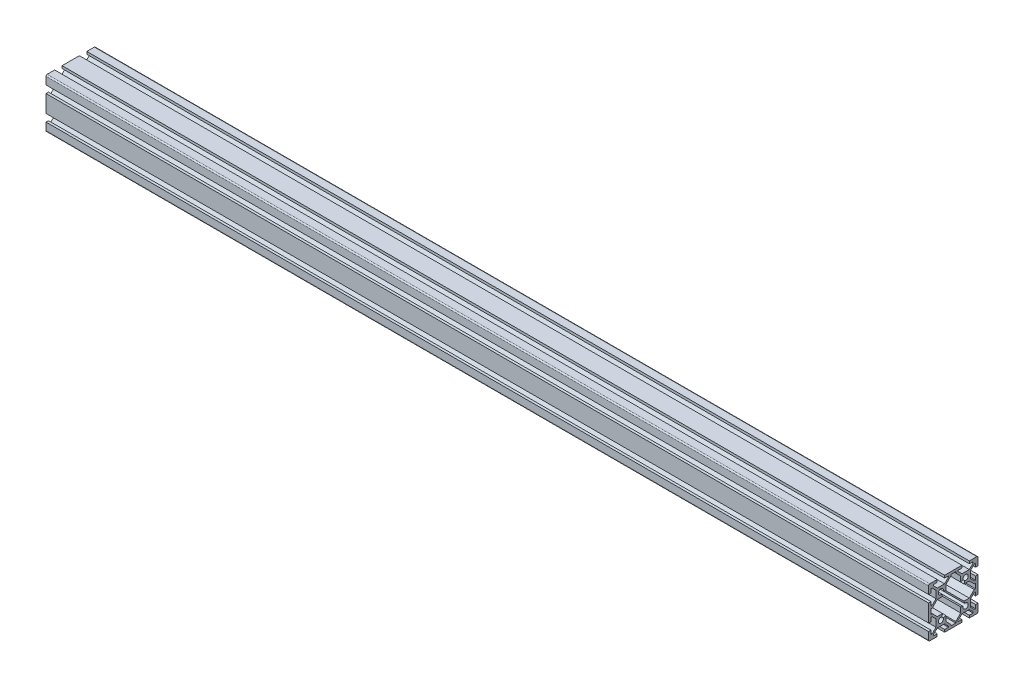
from build123d import *

# Parameters (mm, degrees)
BOSS_EXTRUDE1_DEPTH = 714


with BuildPart() as part:
    # Sketch1 → Boss-Extrude1 (new body)
    with BuildSketch(Plane(origin=(0, 0, 0), x_dir=(0, 0, -1), z_dir=(1, 0, 0))):
        with BuildLine():
            Line((-20, 19), (-20, 13))
            Line((-20, 13), (-18, 13))
            Line((-18, 13), (-18, 16))
            Line((-18, 16), (-17.060660172, 16))
            Line((-17.060660172, 16), (-14, 12.939339828))
            Line((-14, 12.939339828), (-14, 7.060660172))
            Line((-14, 7.060660172), (-17.060660172, 4))
            Line((-17.060660172, 4), (-18, 4))
            Line((-18, 4), (-18, 7))
            Line((-18, 7), (-20, 7))
            Line((-20, 7), (-20, -7))
            Line((-20, -7), (-18, -7))
            Line((-18, -7), (-18, -4))
            Line((-18, -4), (-17.060660172, -4))
            Line((-17.060660172, -4), (-14, -7.060660172))
            Line((-14, -7.060660172), (-14, -12.939339828))
            Line((-14, -12.939339828), (-17.060660172, -16))
            Line((-17.060660172, -16), (-18, -16))
            Line((-18, -16), (-18, -13))
            Line((-18, -13), (-20, -13))
            Line((-20, -13), (-20, -19))
            ThreePointArc((-20, -19), (-19.707106781, -19.707106781), (-19, -20))
            Line((-19, -20), (-13, -20))
            Line((-13, -20), (-13, -18))
            Line((-13, -18), (-16, -18))
            Line((-16, -18), (-16, -17.060660172))
            Line((-16, -17.060660172), (-12.939339828, -14))
            Line((-12.939339828, -14), (-7.060660172, -14))
            Line((-7.060660172, -14), (-4, -17.060660172))
            Line((-4, -17.060660172), (-4, -18))
            Line((-4, -18), (-7, -18))
            Line((-7, -18), (-7, -20))
            Line((-7, -20), (7, -20))
            Line((7, -20), (7, -18))
            Line((7, -18), (4, -18))
            Line((4, -18), (4, -17.060660172))
            Line((4, -17.060660172), (7.060660172, -14))
            Line((7.060660172, -14), (12.939339828, -14))
            Line((12.939339828, -14), (16, -17.060660172))
            Line((16, -17.060660172), (16, -18))
            Line((16, -18), (13, -18))
            Line((13, -18), (13, -20))
            Line((13, -20), (19, -20))
            ThreePointArc((19, -20), (19.707106781, -19.707106781), (20, -19))
            Line((20, -19), (20, -13))
            Line((20, -13), (18, -13))
            Line((18, -13), (18, -16))
            Line((18, -16), (17.060660172, -16))
            Line((17.060660172, -16), (14, -12.939339828))
            Line((14, -12.939339828), (14, -7.060660172))
            Line((14, -7.060660172), (17.060660172, -4))
            Line((17.060660172, -4), (18, -4))
            Line((18, -4), (18, -7))
            Line((18, -7), (20, -7))
            Line((20, -7), (20, 7))
            Line((20, 7), (18, 7))
            Line((18, 7), (18, 4))
            Line((18, 4), (17.060660172, 4))
            Line((17.060660172, 4), (14, 7.060660172))
            Line((14, 7.060660172), (14, 12.939339828))
            Line((14, 12.939339828), (17.060660172, 16))
            Line((17.060660172, 16), (18, 16))
            Line((18, 16), (18, 13))
            Line((18, 13), (20, 13))
            Line((20, 13), (20, 19))
            ThreePointArc((20, 19), (19.707106781, 19.707106781), (19, 20))
            Line((19, 20), (13, 20))
            Line((13, 20), (13, 18))
            Line((13, 18), (16, 18))
            Line((16, 18), (16, 17.060660172))
            Line((16, 17.060660172), (12.939339828, 14))
            Line((12.939339828, 14), (7.060660172, 14))
            Line((7.060660172, 14), (4, 17.060660172))
            Line((4, 17.060660172), (4, 18))
            Line((4, 18), (7, 18))
            Line((7, 18), (7, 20))
            Line((7, 20), (-7, 20))
            Line((-7, 20), (-7, 18))
            Line((-7, 18), (-4, 18))
            Line((-4, 18), (-4, 17.060660172))
            Line((-4, 17.060660172), (-7.060660172, 14))
            Line((-7.060660172, 14), (-12.939339828, 14))
            Line((-12.939339828, 14), (-16, 17.060660172))
            Line((-16, 17.060660172), (-16, 18))
            Line((-16, 18), (-13, 18))
            Line((-13, 18), (-13, 20))
            Line((-13, 20), (-19, 20))
            ThreePointArc((-19, 20), (-19.707106781, 19.707106781), (-20, 19))
        make_face()
        with BuildLine():
            Line((-16.939339828, 2), (-18, 2))
            Line((-18, 2), (-18, -2))
            Line((-18, -2), (-16.939339828, -2))
            Line((-16.939339828, -2), (-12.939339828, -6))
            Line((-12.939339828, -6), (-8.666662697, -6))
            Line((-8.666662697, -6), (-9.335919912, -8.007765667))
            ThreePointArc((-9.335919912, -8.007765667), (-11.48492424, -11.48492424), (-8.007765667, -9.335919912))
            Line((-8.007765667, -9.335919912), (-6, -8.666662697))
            Line((-6, -8.666662697), (-6, -12.939339828))
            Line((-6, -12.939339828), (-2, -16.939339828))
            Line((-2, -16.939339828), (-2, -18))
            Line((-2, -18), (2, -18))
            Line((2, -18), (2, -16.939339828))
            Line((2, -16.939339828), (6, -12.939339828))
            Line((6, -12.939339828), (6, -8.666662697))
            Line((6, -8.666662697), (8.007765667, -9.335919912))
            ThreePointArc((8.007765667, -9.335919912), (11.48492424, -11.48492424), (9.335919912, -8.007765667))
            Line((9.335919912, -8.007765667), (8.666662697, -6))
            Line((8.666662697, -6), (12.939339828, -6))
            Line((12.939339828, -6), (16.939339828, -2))
            Line((16.939339828, -2), (18, -2))
            Line((18, -2), (18, 2))
            Line((18, 2), (16.939339828, 2))
            Line((16.939339828, 2), (12.939339828, 6))
            Line((12.939339828, 6), (8.666662697, 6))
            Line((8.666662697, 6), (9.335919912, 8.007765667))
            ThreePointArc((9.335919912, 8.007765667), (11.48492424, 11.48492424), (8.007765667, 9.335919912))
            Line((8.007765667, 9.335919912), (6, 8.666662697))
            Line((6, 8.666662697), (6, 12.939339828))
            Line((6, 12.939339828), (2, 16.939339828))
            Line((2, 16.939339828), (2, 18))
            Line((2, 18), (-2, 18))
            Line((-2, 18), (-2, 16.939339828))
            Line((-2, 16.939339828), (-6, 12.939339828))
            Line((-6, 12.939339828), (-6, 8.666662697))
            Line((-6, 8.666662697), (-8.007765667, 9.335919912))
            ThreePointArc((-8.007765667, 9.335919912), (-11.48492424, 11.48492424), (-9.335919912, 8.007765667))
            Line((-9.335919912, 8.007765667), (-8.666662697, 6))
            Line((-8.666662697, 6), (-12.939339828, 6))
            Line((-12.939339828, 6), (-16.939339828, 2))
        make_face(mode=Mode.SUBTRACT)
    extrude(amount=BOSS_EXTRUDE1_DEPTH)


solid = part.part
